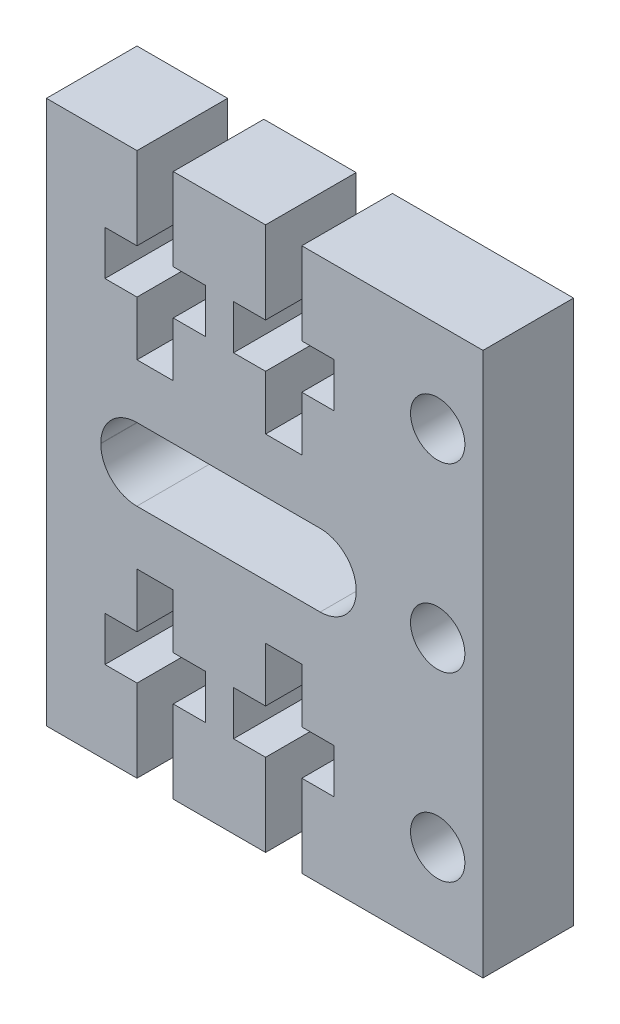
from build123d import *

# Parameters (mm, degrees)
ESBO_O1_W                = 24.096
ESBO_O1_H                = 30
RESSALTO_EXTRUS_O1_DEPTH = 5
ESBO_O2_R                = 1.5
CORTE_EXTRUS_O1_DEPTH    = 10
CORTE_EXTRUS_O2_DEPTH    = 6
CORTE_EXTRUS_O3_DEPTH    = 10
ESBO_O5_R                = 1.5
CORTE_EXTRUS_O4_DEPTH    = 6


with BuildPart() as part:
    # Esboço1 → Ressalto-extrusão1 (new body)
    with BuildSketch(Plane.XY):
        with Locations((-8.476916648, -30.459463918)):
            Rectangle(ESBO_O1_W, ESBO_O1_H)
    extrude(amount=RESSALTO_EXTRUS_O1_DEPTH)

    # Esboço2 → Corte-extrusão1 (cut)
    with BuildSketch(Plane(origin=(0, 0, 0), x_dir=(-1, 0, 0), z_dir=(0, 0, -1))):
        with Locations((-1.071083352, -30.459463918)):
            Circle(ESBO_O2_R)
        with Locations((-1.071083352, -20.459463918)):
            Circle(ESBO_O2_R)
    extrude(amount=-CORTE_EXTRUS_O1_DEPTH, mode=Mode.SUBTRACT)

    # Esboço3 → Corte-extrusão2 (cut, through all)
    with BuildSketch(Plane(origin=(0, 0, 0), x_dir=(-1, 0, 0), z_dir=(0, 0, -1))):
        Polygon((15.524916648, -15.459463918), (13.524916648, -15.459463918), (13.524916648, -20.009463918), (11.754916648, -20.009463918), (11.754916648, -22.459463918), (13.524916648, -22.459463918), (13.524916648, -25.459463918), (15.524916648, -25.459463918), (15.524916648, -22.459463918), (17.294916648, -22.459463918), (17.294916648, -20.009463918), (15.524916648, -20.009463918), align=None)
        Polygon((8.428916648, -15.459463918), (6.428916648, -15.459463918), (6.428916648, -20.009463918), (4.658916648, -20.009463918), (4.658916648, -22.459463918), (6.428916648, -22.459463918), (6.428916648, -25.459463918), (8.428916648, -25.459463918), (8.428916648, -22.459463918), (10.198916648, -22.459463918), (10.198916648, -20.009463918), (8.428916648, -20.009463918), align=None)
        Polygon((6.428916648, -40.909463918), (4.658916648, -40.909463918), (4.658916648, -38.459463918), (6.428916648, -38.459463918), (6.428916648, -35.459463918), (8.428916648, -35.459463918), (8.428916648, -38.459463918), (10.198916648, -38.459463918), (10.198916648, -40.909463918), (8.428916648, -40.909463918), (8.428916648, -45.459463918), (6.428916648, -45.459463918), align=None)
        Polygon((13.524916648, -40.909463918), (11.754916648, -40.909463918), (11.754916648, -38.459463918), (13.524916648, -38.459463918), (13.524916648, -35.459463918), (15.524916648, -35.459463918), (15.524916648, -38.459463918), (17.294916648, -38.459463918), (17.294916648, -40.909463918), (15.524916648, -40.909463918), (15.524916648, -45.459463918), (13.524916648, -45.459463918), align=None)
    extrude(amount=-CORTE_EXTRUS_O2_DEPTH, mode=Mode.SUBTRACT)

    # Esboço4 → Corte-extrusão3 (cut)
    with BuildSketch(Plane(origin=(0, 0, 0), x_dir=(-1, 0, 0), z_dir=(0, 0, -1))):
        with BuildLine():
            Line((15.534916648, -32.459463918), (5.415284958, -32.459463918))
            ThreePointArc((5.415284958, -32.459463918), (4.008142463, -31.876606412), (3.425284958, -30.469463918))
            Line((3.425284958, -30.469463918), (3.425284958, -30.449463918))
            ThreePointArc((3.425284958, -30.449463918), (4.008142463, -29.042321423), (5.415284958, -28.459463918))
            Line((5.415284958, -28.459463918), (15.534916648, -28.459463918))
            ThreePointArc((15.534916648, -28.459463918), (16.942059143, -29.042321423), (17.524916648, -30.449463918))
            Line((17.524916648, -30.449463918), (17.524916648, -30.469463918))
            ThreePointArc((17.524916648, -30.469463918), (16.942059143, -31.876606412), (15.534916648, -32.459463918))
        make_face()
    extrude(amount=-CORTE_EXTRUS_O3_DEPTH, mode=Mode.SUBTRACT)

    # Esboço5 → Corte-extrusão4 (cut, through all)
    with BuildSketch(Plane.XY.offset(5)):
        with Locations((1.071083352, -40.459463918)):
            Circle(ESBO_O5_R)
    extrude(amount=-CORTE_EXTRUS_O4_DEPTH, mode=Mode.SUBTRACT)


solid = part.part
